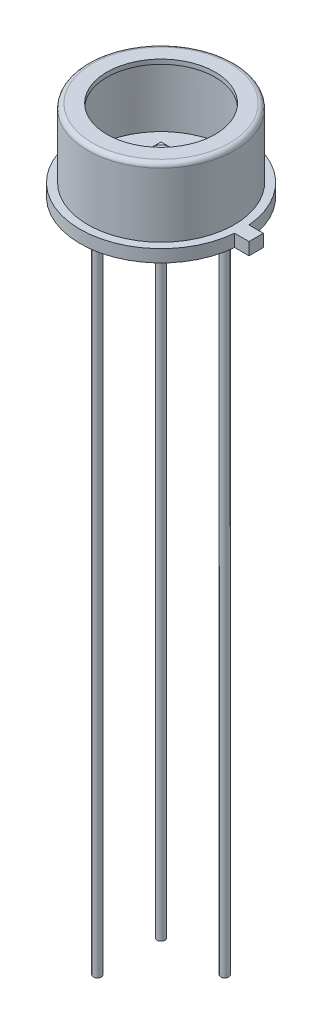
from build123d import *

# Parameters (mm, degrees)
SKETCH2_R           = 4.572
BOSS_EXTRUDE1_DEPTH = 0.446
BOSS_EXTRUDE2_START = -2.0792
SKETCH3_W           = 1.2
SKETCH3_H           = 1.2
BOSS_EXTRUDE2_DEPTH = 0.05
SKETCH8_R           = 0.51
BOSS_EXTRUDE6_DEPTH = 0.1
SKETCH5_R           = 0.225
BOSS_EXTRUDE4_DEPTH = 38
SKETCH10_W          = 0.81
SKETCH10_H          = 0.81
BOSS_EXTRUDE7_DEPTH = 0.7


with BuildPart() as part:
    # Sketch1 → Revolve-Thin2 (revolve)
    with BuildSketch(Plane.XY, mode=Mode.PRIVATE) as revolve_thin2_sk:
        with BuildLine():
            Line((4.572, 0), (4.572, 0.7))
            Line((4.572, 0.7), (4.13, 0.7))
            Line((4.13, 0.7), (4.13, 4.318))
            ThreePointArc((4.13, 4.318), (4.055605122, 4.497605122), (3.876, 4.572))
            Line((3.876, 4.572), (3.05, 4.572))
            Line((3.05, 4.572), (3.05, 4.318))
            Line((3.05, 4.318), (3.876, 4.318))
            Line((3.876, 4.318), (3.876, 0.446))
            Line((3.876, 0.446), (4.318, 0.446))
            Line((4.318, 0.446), (4.318, 0))
            Line((4.318, 0), (4.572, 0))
        make_face()
    revolve(revolve_thin2_sk.sketch.rotate(Axis((0, 0, 0), (0, 1, 0)), 90), axis=Axis((0, 0, 0), (0, 1, 0)))  # turned: the seam where the file's is

    # Sketch2 → Boss-Extrude1 (add)
    with BuildSketch(Plane.XZ):
        with Locations(Location((0, 0, 0), (0, 0, 270))):  # turned: the seam where the file's is
            Circle(SKETCH2_R)
    extrude(amount=-BOSS_EXTRUDE1_DEPTH)

    # Sketch5 → Boss-Extrude4 (add)
    with BuildSketch(Plane.XZ):
        with Locations(Location((-1.796051224, -1.796051224, 0), (0, 0, 90))):  # turned: the seam where the file's is
            Circle(SKETCH5_R)
        with Locations(Location((1.796051224, -1.796051224, 0), (0, 0, 90))):  # turned: the seam where the file's is
            Circle(SKETCH5_R)
        with Locations(Location((-1.796051224, 1.796051224, 0), (0, 0, 90))):  # turned: the seam where the file's is
            Circle(SKETCH5_R)
    extrude(amount=BOSS_EXTRUDE4_DEPTH)

    # Sketch10 → Boss-Extrude7 (add)
    with BuildSketch(Plane.XZ):
        with Locations((4.95902668, 0)):
            Rectangle(SKETCH10_W, SKETCH10_H)
    extrude(amount=-BOSS_EXTRUDE7_DEPTH)


with BuildPart() as body_2:
    # Sketch3 → Boss-Extrude2 (new body)
    with BuildSketch(Plane.XZ.offset(BOSS_EXTRUDE2_START)):
        Rectangle(SKETCH3_W, SKETCH3_H)
    extrude(amount=BOSS_EXTRUDE2_DEPTH)

    # Sketch8 → Boss-Extrude6 (add)
    with BuildSketch(Plane(origin=(0, 2.0792, 0), x_dir=(-1, 0, 0), z_dir=(0, 1, 0))):
        with Locations(Location((0, 0, 0), (0, 0, 270))):  # turned: the seam where the file's is
            Circle(SKETCH8_R)
    extrude(amount=BOSS_EXTRUDE6_DEPTH)


solid = Compound([part.part, body_2.part])
